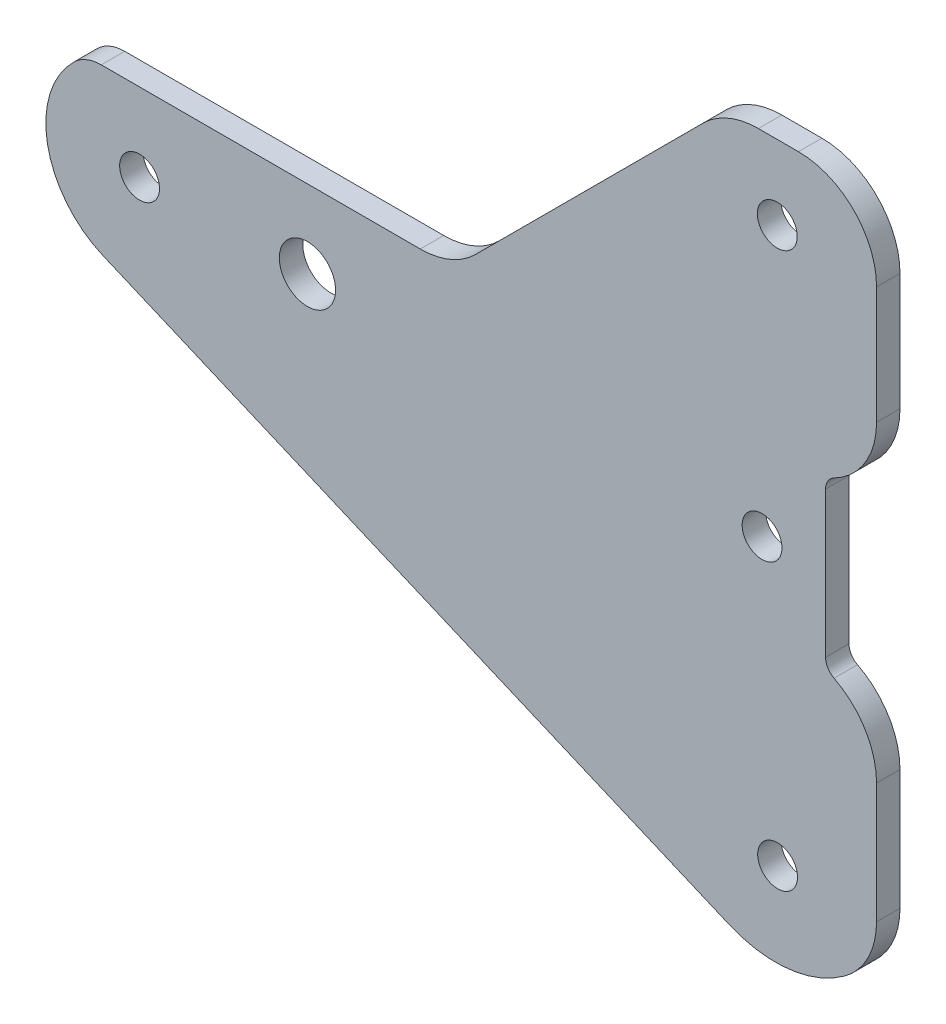
from build123d import *

# Parameters (mm, degrees)
SKETCH1_R           = 2.55
SKETCH1_R_2         = 3.6
BOSS_EXTRUDE1_DEPTH = 3


with BuildPart() as part:
    # Sketch1 → Boss-Extrude1 (new body)
    with BuildSketch(Plane.XY):
        with BuildLine():
            Line((-40.320217865, 38.096664926), (0.519782135, 38.096664926))
            ThreePointArc((0.519782135, 38.096664926), (4.346616459, 38.857869601), (7.590849947, 41.025597114))
            Line((7.590849947, 41.025597114), (36.7307204, 70.165467567))
            ThreePointArc((36.7307204, 70.165467567), (39.974953888, 72.33319508), (43.801788211, 73.094399755))
            Line((43.801788211, 73.094399755), (48.931788211, 73.094399755))
            ThreePointArc((48.931788211, 73.094399755), (56.002856023, 70.165467567), (58.931788211, 63.094399755))
            Line((58.931788211, 63.094399755), (58.931788211, 48.094399755))
            ThreePointArc((58.931788211, 48.094399755), (57.46359146, 42.87823897), (53.490121545, 39.193748249))
            ThreePointArc((53.490121545, 39.193748249), (52.695427562, 38.456850105), (52.401788211, 37.413617948))
            Line((52.401788211, 37.413617948), (52.401788211, 18.773617948))
            ThreePointArc((52.401788211, 18.773617948), (52.695427562, 17.730385791), (53.490121545, 16.993487647))
            ThreePointArc((53.490121545, 16.993487647), (57.46359146, 13.308996927), (58.931788211, 8.092836142))
            Line((58.931788211, 8.092836142), (58.931788211, -7.287163858))
            ThreePointArc((58.931788211, -7.287163858), (57.846780817, -11.817385358), (54.827206843, -15.364542093))
            ThreePointArc((54.827206843, -15.364542093), (47.694417569, -18.15064712), (40.115883144, -17.052976855))
            Line((40.115883144, -17.052976855), (-40.115883144, 17.052976855))
            ThreePointArc((-40.115883144, 17.052976855), (-47.212985277, 25.870194867), (-43.819425953, 36.668155197))
            ThreePointArc((-43.819425953, 36.668155197), (-42.209999419, 37.725782086), (-40.320217865, 38.096664926))
        make_face()
        with Locations((-35.421326542, 28.096578546)):
            Circle(SKETCH1_R, mode=Mode.SUBTRACT)
        with Locations((-13.931326542, 28.096578546)):
            Circle(SKETCH1_R_2, mode=Mode.SUBTRACT)
        with Locations((46.221788211, 63.594399755)):
            Circle(SKETCH1_R, mode=Mode.SUBTRACT)
        with Locations((44.271788211, 28.094399755)):
            Circle(SKETCH1_R, mode=Mode.SUBTRACT)
        with Locations((46.264570837, -7.409030505)):
            Circle(SKETCH1_R, mode=Mode.SUBTRACT)
    extrude(amount=BOSS_EXTRUDE1_DEPTH)


solid = part.part
